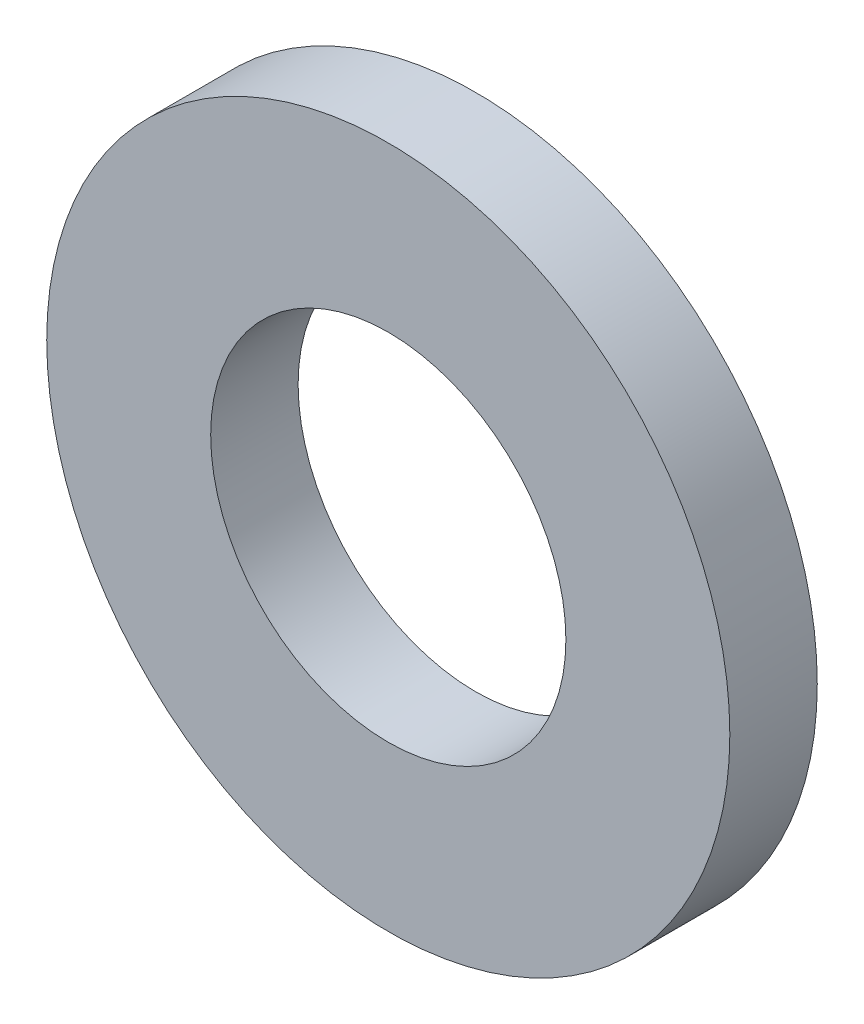
from build123d import *

# Parameters (mm, degrees)
SKETCH1_R           = 6.25
SKETCH1_R_2         = 3.25
BOSS_EXTRUDE1_DEPTH = 1.6


with BuildPart() as part:
    # Sketch1 → Boss-Extrude1 (new body)
    with BuildSketch(Plane.XY):
        Circle(SKETCH1_R)
        Circle(SKETCH1_R_2, mode=Mode.SUBTRACT)
    extrude(amount=BOSS_EXTRUDE1_DEPTH)


solid = part.part
